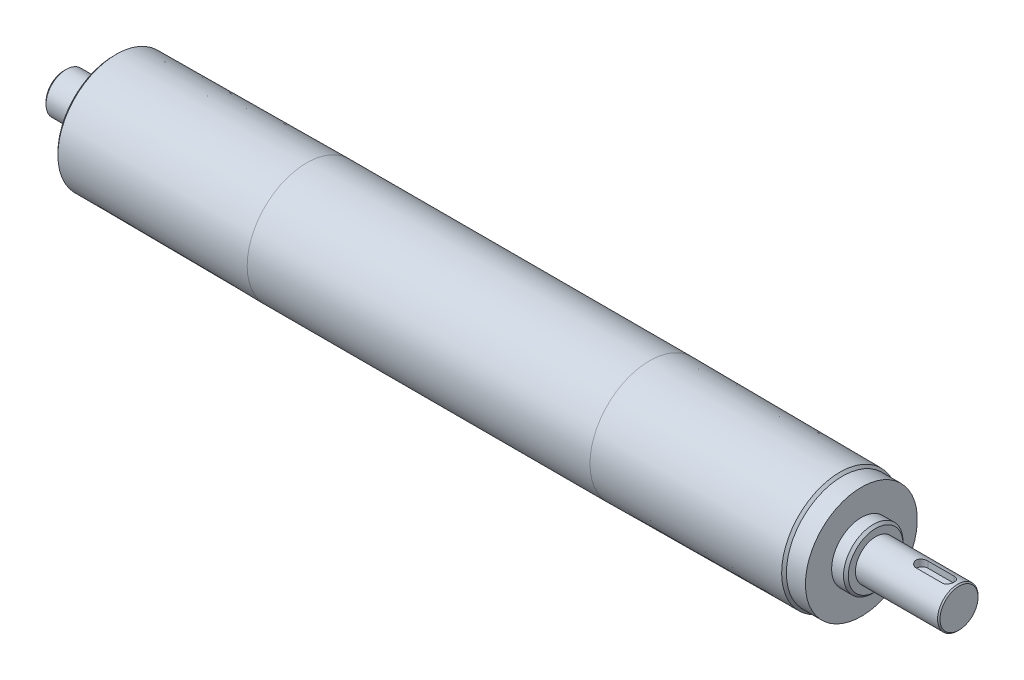
from build123d import *

# Parameters (mm, degrees)
EXTRUDE1_DEPTH = 150


with BuildPart() as part:
    # Sketch1 → Revolve1 (revolve)
    with BuildSketch(Plane(origin=(0, 0, 0), x_dir=(1, 0, 0), z_dir=(0, 1, 0)), mode=Mode.PRIVATE) as revolve1_sk:
        Polygon((-72, 25), (72, 25), (152, 24.5), (153, 23.5), (161, 23.5), (161, 12.5), (166, 12.5), (167, 11.5), (167, 8.5), (201.5, 8.5), (202, 8), (202, 0), (-174, 0), (-174, 7.5), (-173, 8.5), (-158, 8.5), (-158, 11.5), (-157, 12.5), (-153, 12.5), (-153, 23.5), (-152, 24.5), align=None)
    revolve(revolve1_sk.sketch.rotate(Axis((-174, 0, 0), (1, 0, 0)), 180), axis=Axis((-174, 0, 0), (1, 0, 0)))  # turned: the seam where the file's is

    # Sketch2 → Extrude1 (cut)
    with BuildSketch(Plane(origin=(0, 5.5, 0), x_dir=(-1, 0, 0), z_dir=(0, 1, 0))):
        with BuildLine():
            Line((-197.5, 2.5), (-186.5, 2.5))
            ThreePointArc((-186.5, 2.5), (-184, 0), (-186.5, -2.5))
            Line((-186.5, -2.5), (-197.5, -2.5))
            ThreePointArc((-197.5, -2.5), (-200, 0), (-197.5, 2.5))
        make_face()
    extrude(amount=EXTRUDE1_DEPTH, mode=Mode.SUBTRACT)


solid = part.part
